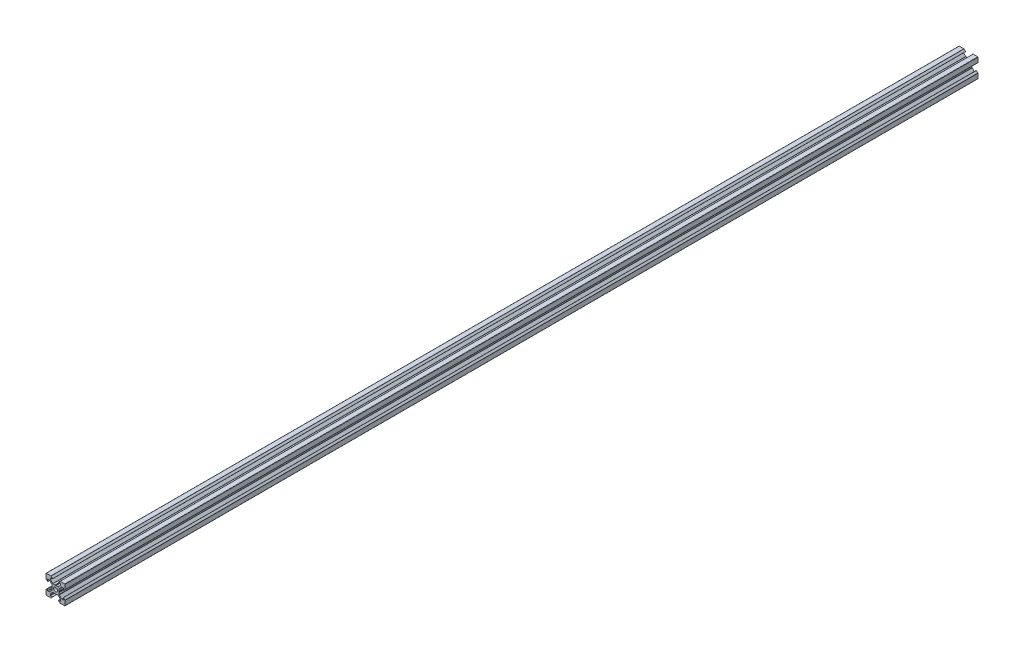
from build123d import *

# Parameters (mm, degrees)
BOSS_EXTRU_1_DEPTH = 960


with BuildPart() as part:
    # Esquisse1 → Boss.-Extru.1 (new body)
    with BuildSketch(Plane.XY):
        with BuildLine():
            Line((18.774857412, -2.895228684), (18.774857412, -4.894568513))
            ThreePointArc((18.774857412, -4.894568513), (18.686989447, -5.106700547), (18.474857412, -5.194568513))
            Line((18.474857412, -5.194568513), (17.259121481, -5.194568513))
            ThreePointArc((17.259121481, -5.194568513), (17.144316451, -5.171732372), (17.046989447, -5.106700547))
            Line((17.046989447, -5.106700547), (14.56338555, -2.62309665))
            ThreePointArc((14.56338555, -2.62309665), (14.498353724, -2.525769645), (14.475517584, -2.410964616))
            Line((14.475517584, -2.410964616), (14.475517584, -0.214843927))
            Line((14.475517584, -0.214843927), (14.175517584, 0.304771316))
            Line((14.175517584, 0.304771316), (14.475517584, 0.824386558))
            Line((14.475517584, 0.824386558), (14.475517584, 3.020507247))
            ThreePointArc((14.475517584, 3.020507247), (14.498353724, 3.135312277), (14.56338555, 3.232639281))
            Line((14.56338555, 3.232639281), (17.046989447, 5.716243178))
            ThreePointArc((17.046989447, 5.716243178), (17.144316451, 5.781275004), (17.259121481, 5.804111144))
            Line((17.259121481, 5.804111144), (18.474857412, 5.804111144))
            ThreePointArc((18.474857412, 5.804111144), (18.686989447, 5.716243178), (18.774857412, 5.504111144))
            Line((18.774857412, 5.504111144), (18.774857412, 3.504771316))
            ThreePointArc((18.774857412, 3.504771316), (18.836589069, 3.412383362), (18.94556809, 3.434060638))
            Line((18.94556809, 3.434060638), (20.486989447, 4.975481994))
            ThreePointArc((20.486989447, 4.975481994), (20.552021272, 5.072808998), (20.574857412, 5.187614028))
            Line((20.574857412, 5.187614028), (20.574857412, 10.004771316))
            ThreePointArc((20.574857412, 10.004771316), (20.486989447, 10.21690335), (20.274857412, 10.304771316))
            Line((20.274857412, 10.304771316), (15.457700125, 10.304771316))
            ThreePointArc((15.457700125, 10.304771316), (15.342895095, 10.281935175), (15.24556809, 10.21690335))
            Line((15.24556809, 10.21690335), (13.704146734, 8.675481994))
            ThreePointArc((13.704146734, 8.675481994), (13.682469459, 8.566502972), (13.774857412, 8.504771316))
            Line((13.774857412, 8.504771316), (15.77419724, 8.504771316))
            ThreePointArc((15.77419724, 8.504771316), (15.986329275, 8.41690335), (16.07419724, 8.204771316))
            Line((16.07419724, 8.204771316), (16.07419724, 6.989035384))
            ThreePointArc((16.07419724, 6.989035384), (16.0513611, 6.874230355), (15.986329275, 6.77690335))
            Line((15.986329275, 6.77690335), (13.502725378, 4.293299453))
            ThreePointArc((13.502725378, 4.293299453), (13.405398373, 4.228267628), (13.290593344, 4.205431487))
            Line((13.290593344, 4.205431487), (11.094472654, 4.205431487))
            Line((11.094472654, 4.205431487), (10.574857412, 3.905431487))
            Line((10.574857412, 3.905431487), (10.05524217, 4.205431487))
            Line((10.05524217, 4.205431487), (7.859121481, 4.205431487))
            ThreePointArc((7.859121481, 4.205431487), (7.744316451, 4.228267628), (7.646989447, 4.293299453))
            Line((7.646989447, 4.293299453), (5.16338555, 6.77690335))
            ThreePointArc((5.16338555, 6.77690335), (5.098353724, 6.874230355), (5.075517584, 6.989035384))
            Line((5.075517584, 6.989035384), (5.075517584, 8.204771316))
            ThreePointArc((5.075517584, 8.204771316), (5.16338555, 8.41690335), (5.375517584, 8.504771316))
            Line((5.375517584, 8.504771316), (7.374857412, 8.504771316))
            ThreePointArc((7.374857412, 8.504771316), (7.467245365, 8.566502972), (7.44556809, 8.675481994))
            Line((7.44556809, 8.675481994), (5.904146734, 10.21690335))
            ThreePointArc((5.904146734, 10.21690335), (5.806819729, 10.281935175), (5.6920147, 10.304771316))
            Line((5.6920147, 10.304771316), (0.874857412, 10.304771316))
            ThreePointArc((0.874857412, 10.304771316), (0.662725378, 10.21690335), (0.574857412, 10.004771316))
            Line((0.574857412, 10.004771316), (0.574857412, 5.187614028))
            ThreePointArc((0.574857412, 5.187614028), (0.597693552, 5.072808998), (0.662725378, 4.975481994))
            Line((0.662725378, 4.975481994), (2.204146734, 3.434060638))
            ThreePointArc((2.204146734, 3.434060638), (2.313125755, 3.412383362), (2.374857412, 3.504771316))
            Line((2.374857412, 3.504771316), (2.374857412, 5.504111144))
            ThreePointArc((2.374857412, 5.504111144), (2.462725378, 5.716243178), (2.674857412, 5.804111144))
            Line((2.674857412, 5.804111144), (3.890593344, 5.804111144))
            ThreePointArc((3.890593344, 5.804111144), (4.005398373, 5.781275004), (4.102725378, 5.716243178))
            Line((4.102725378, 5.716243178), (6.586329275, 3.232639281))
            ThreePointArc((6.586329275, 3.232639281), (6.6513611, 3.135312277), (6.67419724, 3.020507247))
            Line((6.67419724, 3.020507247), (6.67419724, 0.824386558))
            Line((6.67419724, 0.824386558), (6.97419724, 0.304771316))
            Line((6.97419724, 0.304771316), (6.67419724, -0.214843927))
            Line((6.67419724, -0.214843927), (6.67419724, -2.410964616))
            ThreePointArc((6.67419724, -2.410964616), (6.6513611, -2.525769645), (6.586329275, -2.62309665))
            Line((6.586329275, -2.62309665), (4.102725378, -5.106700547))
            ThreePointArc((4.102725378, -5.106700547), (4.005398373, -5.171732372), (3.890593344, -5.194568513))
            Line((3.890593344, -5.194568513), (2.674857412, -5.194568513))
            ThreePointArc((2.674857412, -5.194568513), (2.462725378, -5.106700547), (2.374857412, -4.894568513))
            Line((2.374857412, -4.894568513), (2.374857412, -2.895228684))
            ThreePointArc((2.374857412, -2.895228684), (2.313125755, -2.802840731), (2.204146734, -2.824518006))
            Line((2.204146734, -2.824518006), (0.662725378, -4.365939362))
            ThreePointArc((0.662725378, -4.365939362), (0.597693552, -4.463266367), (0.574857412, -4.578071397))
            Line((0.574857412, -4.578071397), (0.574857412, -9.395228684))
            ThreePointArc((0.574857412, -9.395228684), (0.662725378, -9.607360719), (0.874857412, -9.695228684))
            Line((0.874857412, -9.695228684), (5.6920147, -9.695228684))
            ThreePointArc((5.6920147, -9.695228684), (5.806819729, -9.672392544), (5.904146734, -9.607360719))
            Line((5.904146734, -9.607360719), (7.44556809, -8.065939362))
            ThreePointArc((7.44556809, -8.065939362), (7.467245365, -7.956960341), (7.374857412, -7.895228684))
            Line((7.374857412, -7.895228684), (5.375517584, -7.895228684))
            ThreePointArc((5.375517584, -7.895228684), (5.16338555, -7.807360719), (5.075517584, -7.595228684))
            Line((5.075517584, -7.595228684), (5.075517584, -6.379492753))
            ThreePointArc((5.075517584, -6.379492753), (5.098353724, -6.264687723), (5.16338555, -6.167360719))
            Line((5.16338555, -6.167360719), (7.646989447, -3.683756822))
            ThreePointArc((7.646989447, -3.683756822), (7.744316451, -3.618724996), (7.859121481, -3.595888856))
            Line((7.859121481, -3.595888856), (10.05524217, -3.595888856))
            Line((10.05524217, -3.595888856), (10.574857412, -3.295888856))
            Line((10.574857412, -3.295888856), (11.094472654, -3.595888856))
            Line((11.094472654, -3.595888856), (13.290593344, -3.595888856))
            ThreePointArc((13.290593344, -3.595888856), (13.405398373, -3.618724996), (13.502725378, -3.683756822))
            Line((13.502725378, -3.683756822), (15.986329275, -6.167360719))
            ThreePointArc((15.986329275, -6.167360719), (16.0513611, -6.264687723), (16.07419724, -6.379492753))
            Line((16.07419724, -6.379492753), (16.07419724, -7.595228684))
            ThreePointArc((16.07419724, -7.595228684), (15.986329275, -7.807360719), (15.77419724, -7.895228684))
            Line((15.77419724, -7.895228684), (13.774857412, -7.895228684))
            ThreePointArc((13.774857412, -7.895228684), (13.682469459, -7.956960341), (13.704146734, -8.065939362))
            Line((13.704146734, -8.065939362), (15.24556809, -9.607360719))
            ThreePointArc((15.24556809, -9.607360719), (15.342895095, -9.672392544), (15.457700125, -9.695228684))
            Line((15.457700125, -9.695228684), (20.274857412, -9.695228684))
            ThreePointArc((20.274857412, -9.695228684), (20.486989447, -9.607360719), (20.574857412, -9.395228684))
            Line((20.574857412, -9.395228684), (20.574857412, -4.578071397))
            ThreePointArc((20.574857412, -4.578071397), (20.552021272, -4.463266367), (20.486989447, -4.365939362))
            Line((20.486989447, -4.365939362), (18.94556809, -2.824518006))
            ThreePointArc((18.94556809, -2.824518006), (18.836589069, -2.802840731), (18.774857412, -2.895228684))
        make_face()
        with BuildLine():
            ThreePointArc((10.574857412, -1.795228684), (12.059781653, -1.180152925), (12.674857412, 0.304771316))
            ThreePointArc((12.674857412, 0.304771316), (12.059781653, 1.789695556), (10.574857412, 2.404771316))
            ThreePointArc((10.574857412, 2.404771316), (9.089933172, 1.789695556), (8.474857412, 0.304771316))
            ThreePointArc((8.474857412, 0.304771316), (9.089933172, -1.180152925), (10.574857412, -1.795228684))
        make_face(mode=Mode.SUBTRACT)
    extrude(amount=BOSS_EXTRU_1_DEPTH)


solid = part.part
